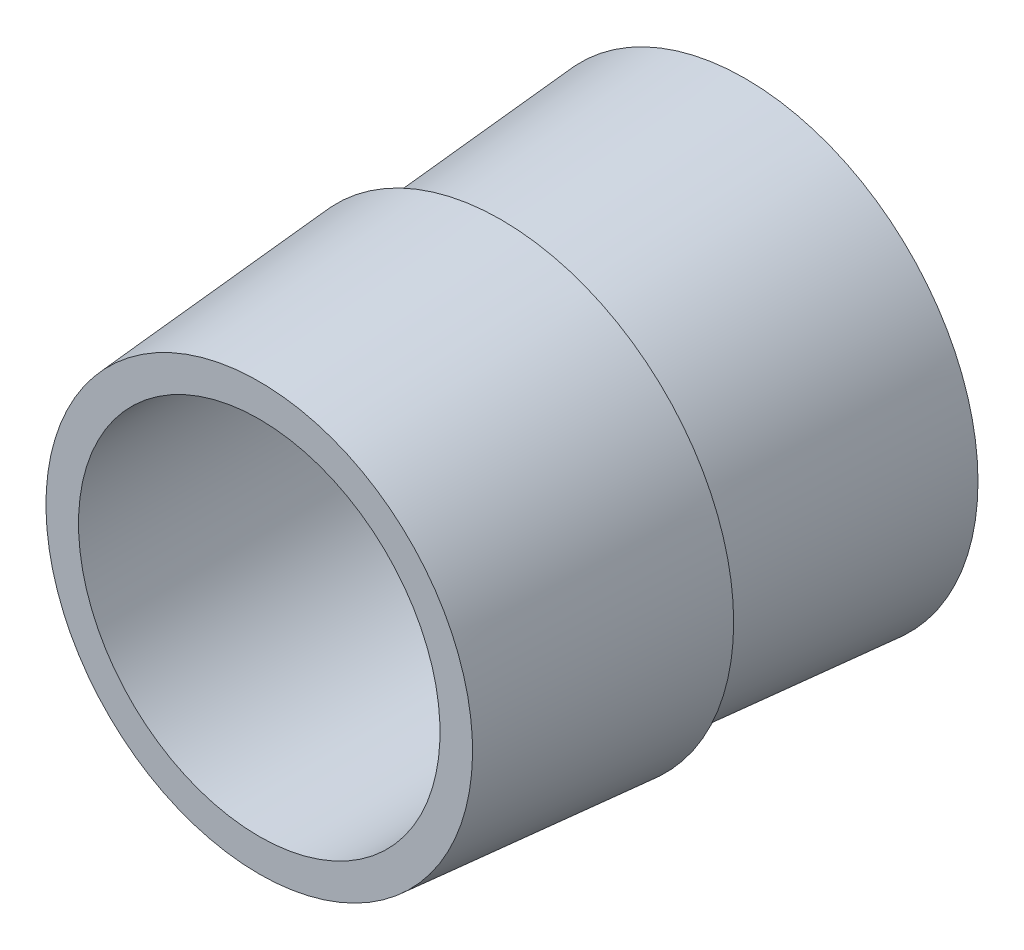
from build123d import *

# Parameters (mm, degrees)
SKETCH7_R          = 2.75
CUT_EXTRUDE3_DEPTH = 8.394010373


with BuildPart() as part:
    # Sketch2 → Revolve2 (revolve)
    with BuildSketch(Plane(origin=(0, 0, 0), x_dir=(0, 0, -1), z_dir=(1, 0, 0))):
        Polygon((-0.541748287, 0.975013223), (-0.541748287, -1.269840707), (6.852262086, -1.269840707), (6.852262086, 1.269840707), (6.852262086, 2.269840707), (3.138076713, 1.975013223), (3.138076713, 2.267113223), (-0.541748287, 1.975013223), (-0.541748287, 1.267113223), align=None)
    revolve(axis=Axis((0, -1.269840707, 0.541748287), (0, 0, -1)))

    # Sketch7 → Cut-Extrude3 (cut, through all)
    with BuildSketch(Plane(origin=(0, 0, -6.852262086), x_dir=(-1, 0, 0), z_dir=(0, 0, -1))):
        with Locations((0, -1.269840707)):
            Circle(SKETCH7_R)
    extrude(amount=-CUT_EXTRUDE3_DEPTH, mode=Mode.SUBTRACT)


solid = part.part
